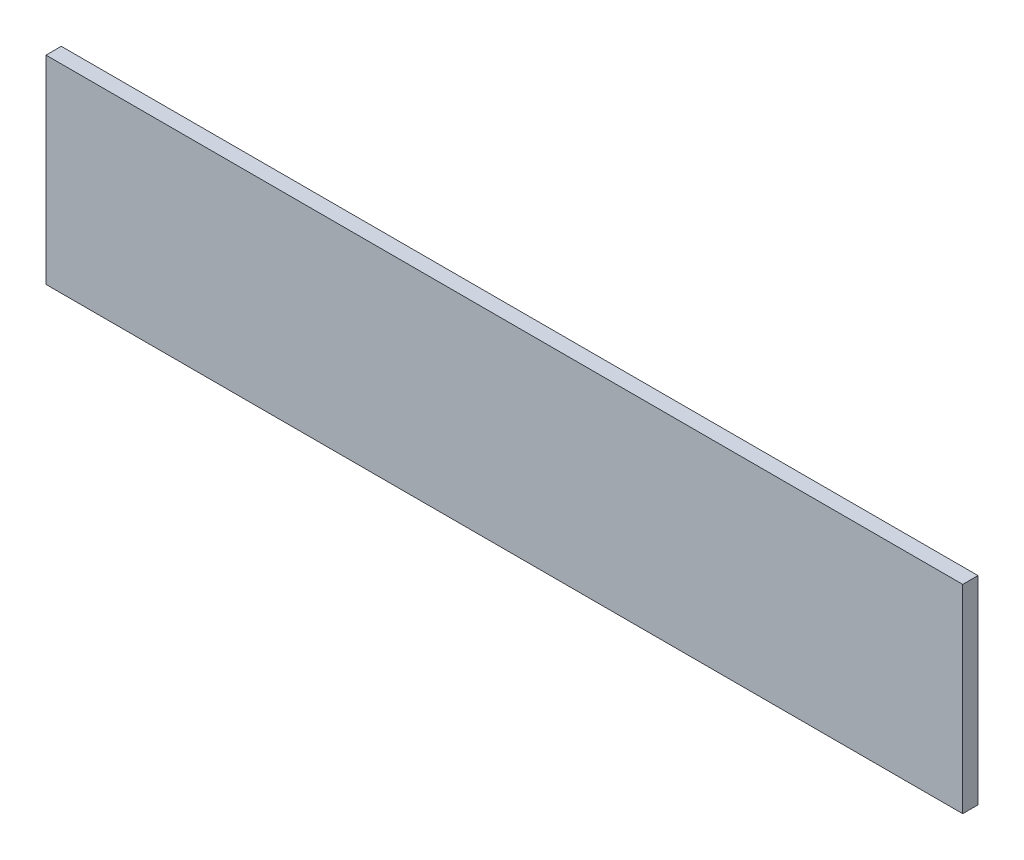
from build123d import *

# Parameters (mm, degrees)
ESQUISSE1_W        = 600
ESQUISSE1_H        = 130
BOSS_EXTRU_1_DEPTH = 10


with BuildPart() as part:
    # Esquisse1 → Boss.-Extru.1 (new body)
    with BuildSketch(Plane.XY):
        with Locations((300, 65)):
            Rectangle(ESQUISSE1_W, ESQUISSE1_H)
    extrude(amount=BOSS_EXTRU_1_DEPTH)


solid = part.part
